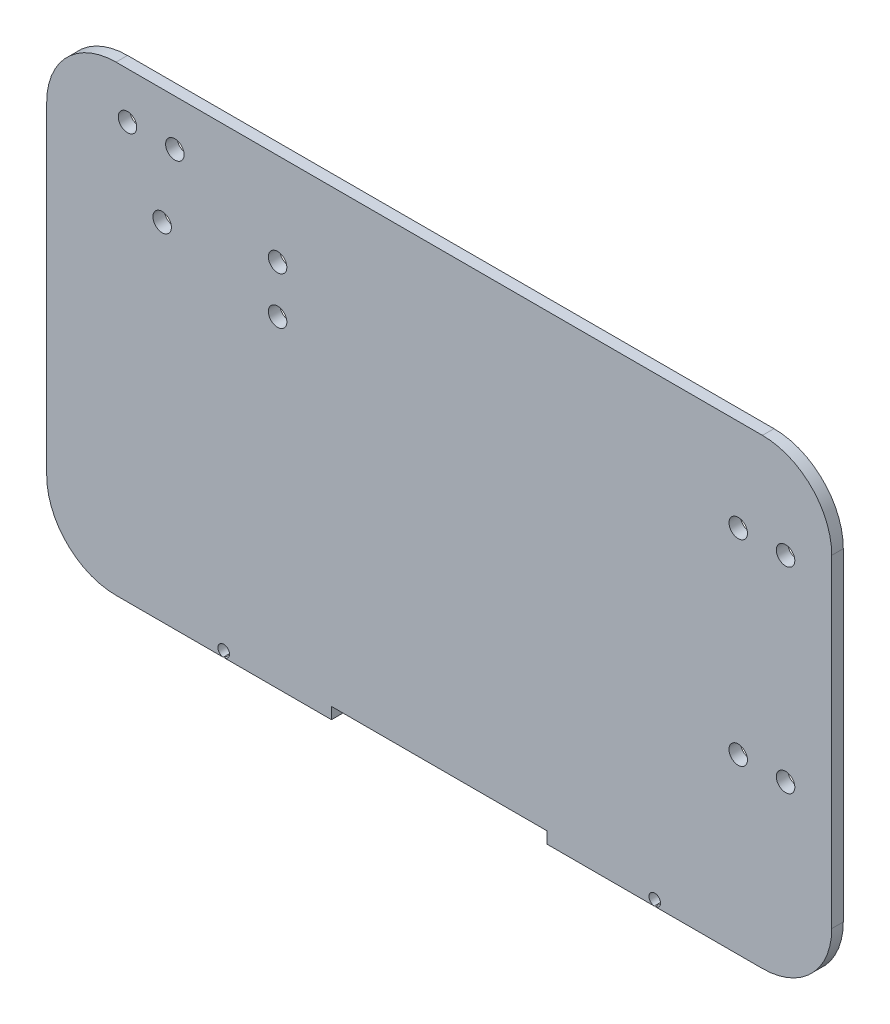
from build123d import *

# Parameters (mm, degrees)
CROQUIS1_R              = 4
SALIENTE_EXTRUIR1_DEPTH = 5
CROQUIS3_W              = 93.333333333
CROQUIS3_H              = 5
CORTAR_EXTRUIR1_DEPTH   = 10
CROQUIS6_R              = 2.5
CORTAR_EXTRUIR2_DEPTH   = 10


with BuildPart() as part:
    # Croquis1 → Saliente-Extruir1 (new body)
    with BuildSketch(Plane.XY):
        with BuildLine():
            Line((-125.472429705, -88.332065653), (154.527570295, -88.332065653))
            ThreePointArc((154.527570295, -88.332065653), (175.740773731, -79.545269088), (184.527570295, -58.332065653))
            Line((184.527570295, -58.332065653), (184.527570295, 81.667934347))
            ThreePointArc((184.527570295, 81.667934347), (175.740773731, 102.881137783), (154.527570295, 111.667934347))
            Line((154.527570295, 111.667934347), (-125.472429705, 111.667934347))
            ThreePointArc((-125.472429705, 111.667934347), (-146.68563314, 102.881137783), (-155.472429705, 81.667934347))
            Line((-155.472429705, 81.667934347), (-155.472429705, -58.332065653))
            ThreePointArc((-155.472429705, -58.332065653), (-146.68563314, -79.545269088), (-125.472429705, -88.332065653))
        make_face()
        with Locations((-105.472429705, 61.667934347)):
            Circle(CROQUIS1_R, mode=Mode.SUBTRACT)
        with Locations((-55.472429705, 71.667934347)):
            Circle(CROQUIS1_R, mode=Mode.SUBTRACT)
        with Locations((-55.472429705, 51.167934347)):
            Circle(CROQUIS1_R, mode=Mode.SUBTRACT)
        with Locations((144.027570295, -13.332065653)):
            Circle(CROQUIS1_R, mode=Mode.SUBTRACT)
        with Locations((164.527570295, -13.332065653)):
            Circle(CROQUIS1_R, mode=Mode.SUBTRACT)
        with Locations((144.027570295, 71.667934347)):
            Circle(CROQUIS1_R, mode=Mode.SUBTRACT)
        with Locations((164.527570295, 71.667934347)):
            Circle(CROQUIS1_R, mode=Mode.SUBTRACT)
        with Locations((-99.972429705, 91.667934347)):
            Circle(CROQUIS1_R, mode=Mode.SUBTRACT)
        with Locations((-120.472429705, 91.667934347)):
            Circle(CROQUIS1_R, mode=Mode.SUBTRACT)
    extrude(amount=SALIENTE_EXTRUIR1_DEPTH)

    # Croquis3 → Cortar-Extruir1 (cut)
    with BuildSketch(Plane.XY.offset(5)):
        with Locations((14.527570296, -85.832065653)):
            Rectangle(CROQUIS3_W, CROQUIS3_H)
    extrude(amount=-CORTAR_EXTRUIR1_DEPTH, mode=Mode.SUBTRACT)

    # Croquis6 → Cortar-Extruir2 (cut)
    with BuildSketch(Plane.XY.offset(5)):
        with Locations((-78.805763038, -85.842065653)):
            Circle(CROQUIS6_R)
        with Locations((107.860903629, -85.842065653)):
            Circle(CROQUIS6_R)
    extrude(amount=-CORTAR_EXTRUIR2_DEPTH, mode=Mode.SUBTRACT)


solid = part.part
